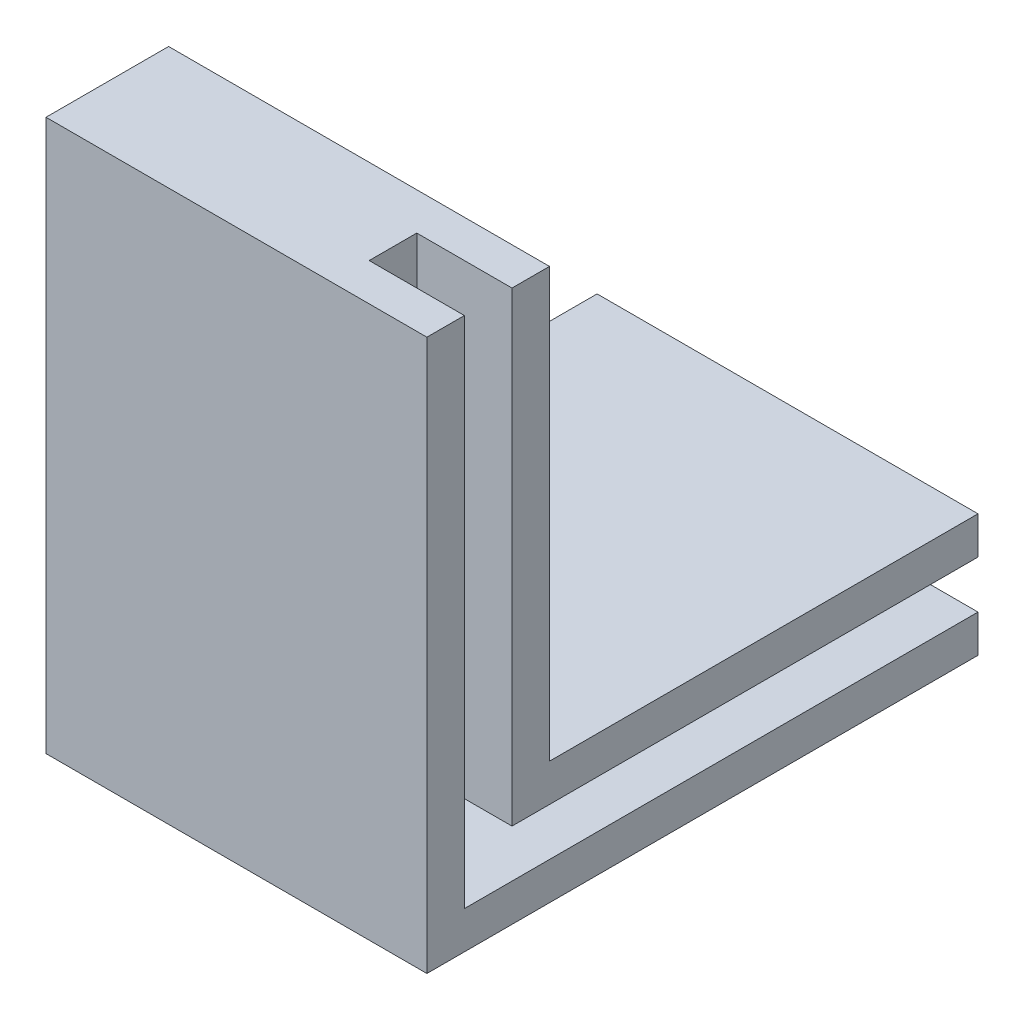
from build123d import *

# Parameters (mm, degrees)
BOSS_EXTRUDE2_DEPTH = 50.8
CUT_EXTRUDE1_DEPTH  = 12.7


with BuildPart() as part:
    # Sketch2 → Boss-Extrude2 (new body)
    with BuildSketch(Plane(origin=(0, 0, 0), x_dir=(0, 0, -1), z_dir=(1, 0, 0))):
        Polygon((0, 0), (73.5, 0), (73.5, 16.35), (16.35, 16.35), (16.35, 73.5), (0, 73.5), align=None)
    extrude(amount=BOSS_EXTRUDE2_DEPTH)

    # Sketch3 → Cut-Extrude1 (cut)
    with BuildSketch(Plane(origin=(50.8, 0, 0), x_dir=(0, 0, -1), z_dir=(1, 0, 0))):
        Polygon((5, 5), (73.5, 5), (73.5, 11.35), (11.35, 11.35), (11.35, 73.5), (5, 73.5), align=None)
    extrude(amount=-CUT_EXTRUDE1_DEPTH, mode=Mode.SUBTRACT)


solid = part.part
